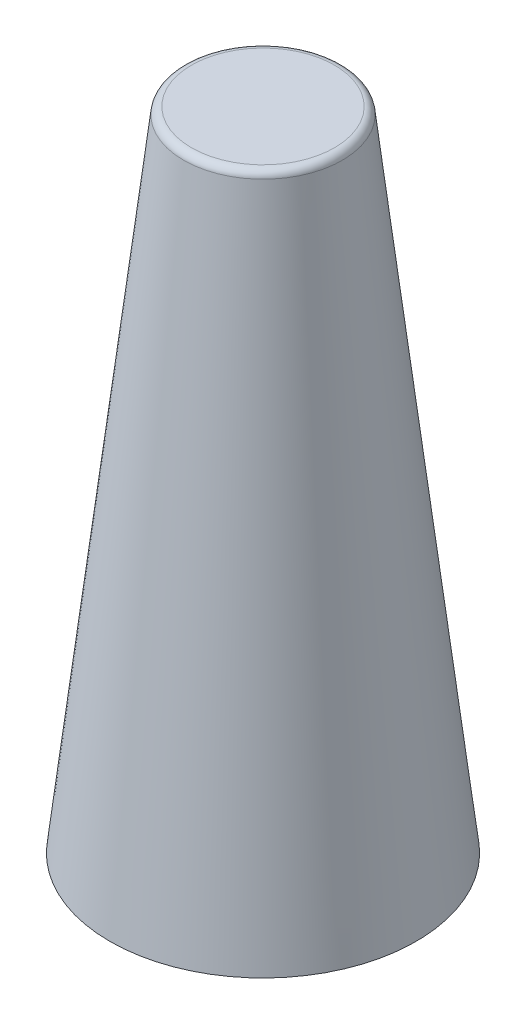
from build123d import *

# Parameters (mm, degrees)
FILLET1_R = 10


with BuildPart() as part:
    # Sketch1 → Revolve1 (revolve)
    with BuildSketch(Plane.XY, mode=Mode.PRIVATE) as revolve1_sk:
        Polygon((0, 406.66959799), (0, 416.66959799), (-100, 416.66959799), (-195, -406.33040201), (0, -406.33040201), (0, -396.33040201), (-188.812485751, -396.33040201), (-96.121112726, 406.66959799), align=None)
    revolve(revolve1_sk.sketch.rotate(Axis((0, 416.66959799, 0), (0, -1, 0)), 270), axis=Axis((0, 416.66959799, 0), (0, -1, 0)))

    # Fillet1
    fillet1_edges = [part.edges().sort_by_distance(p)[0] for p in [
        (0, 416.66959799, -100),
    ]]
    fillet(fillet1_edges, radius=FILLET1_R)


solid = part.part
